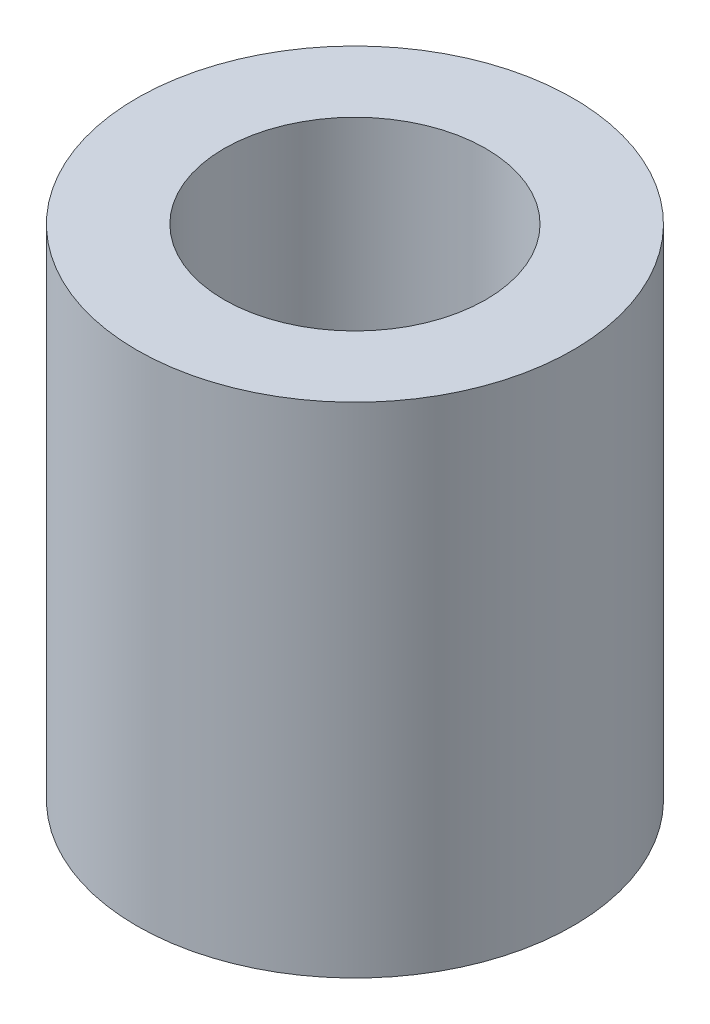
from build123d import *

# Parameters (mm, degrees)
SKETCH_1_R      = 3.5
SKETCH_1_R_2    = 2.1
EXTRUDE_1_DEPTH = 8


with BuildPart() as part:
    # 草图1 → 凸台-拉伸1 (new body)
    with BuildSketch(Plane(origin=(0, 0, 0), x_dir=(1, 0, 0), z_dir=(0, 1, 0))):
        Circle(SKETCH_1_R)
        Circle(SKETCH_1_R_2, mode=Mode.SUBTRACT)
    extrude(amount=EXTRUDE_1_DEPTH)


solid = part.part
